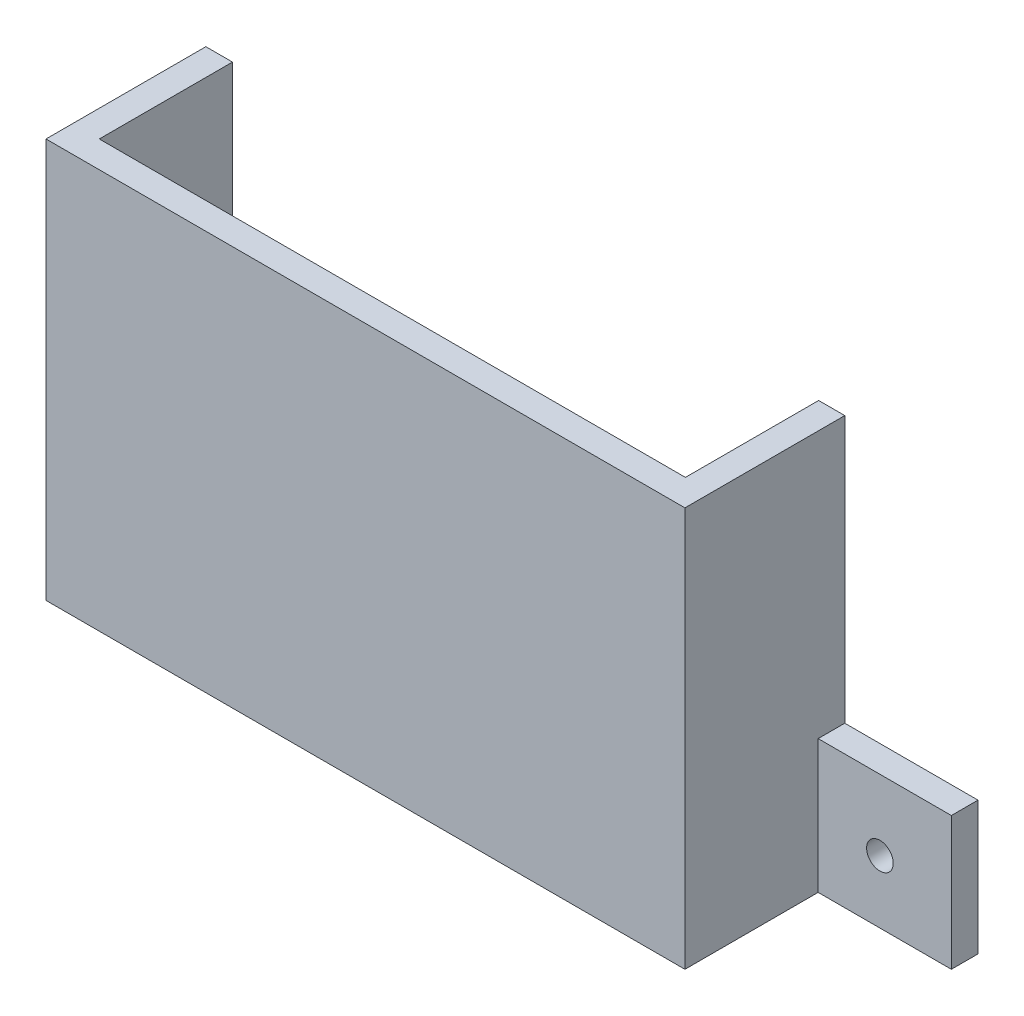
from build123d import *

# Parameters (mm, degrees)
EXTRUDE_1_DEPTH     = 30
SKETCH_2_W          = 20
SKETCH_2_H          = 2
EXTRUDE_2_DEPTH     = 6
SKETCH_3_W          = 10
SKETCH_3_H          = 10
EXTRUDE_5_DEPTH     = 10
SKETCH_3_2_W        = 10
SKETCH_3_2_H        = 10
CUT_EXTRUDE_1_DEPTH = 8
SKETCH_4_R          = 1
CUT_EXTRUDE_2_DEPTH = 15


with BuildPart() as part:
    # 草图1 → 凸台-拉伸1 (new body)
    with BuildSketch(Plane(origin=(0, 0, 0), x_dir=(1, 0, 0), z_dir=(0, 1, 0))):
        Polygon((-38.526315789, 0), (5.473684211, 0), (5.473684211, 10), (7.436715789, 10), (7.436715789, -2), (5.473684211, -2), (-38.526315789, -2), (-40.526315789, -2), (-40.526315789, 10), (-38.526315789, 10), align=None)
    extrude(amount=EXTRUDE_1_DEPTH)

    # 草图2 → 凸台-拉伸2 (add)
    with BuildSketch(Plane.XY):
        with Locations((-16.563284211, 1)):
            Rectangle(SKETCH_2_W, SKETCH_2_H)
    extrude(amount=-EXTRUDE_2_DEPTH)

    # 草图3 → 凸台-拉伸5 (add)
    with BuildSketch(Plane.XY):
        with Locations((-45.526315789, 5)):
            Rectangle(SKETCH_3_W, SKETCH_3_H)
        with Locations((12.436715789, 5)):
            Rectangle(SKETCH_3_W, SKETCH_3_H)
    extrude(amount=-EXTRUDE_5_DEPTH)

    # 草图3<2> → 切除-拉伸1 (cut)
    with BuildSketch(Plane.XY):
        with Locations((-45.526315789, 5)):
            Rectangle(SKETCH_3_2_W, SKETCH_3_2_H)
        with Locations((12.436715789, 5)):
            Rectangle(SKETCH_3_2_W, SKETCH_3_2_H)
    extrude(amount=-CUT_EXTRUDE_1_DEPTH, mode=Mode.SUBTRACT)

    # 草图4 → 切除-拉伸2 (cut)
    with BuildSketch(Plane.XY):
        with Locations((-45.867673878, 4.706880403)):
            Circle(SKETCH_4_R)
        with Locations((12.075128271, 4.706880403)):
            Circle(SKETCH_4_R)
    extrude(amount=-CUT_EXTRUDE_2_DEPTH, mode=Mode.SUBTRACT)


solid = part.part
